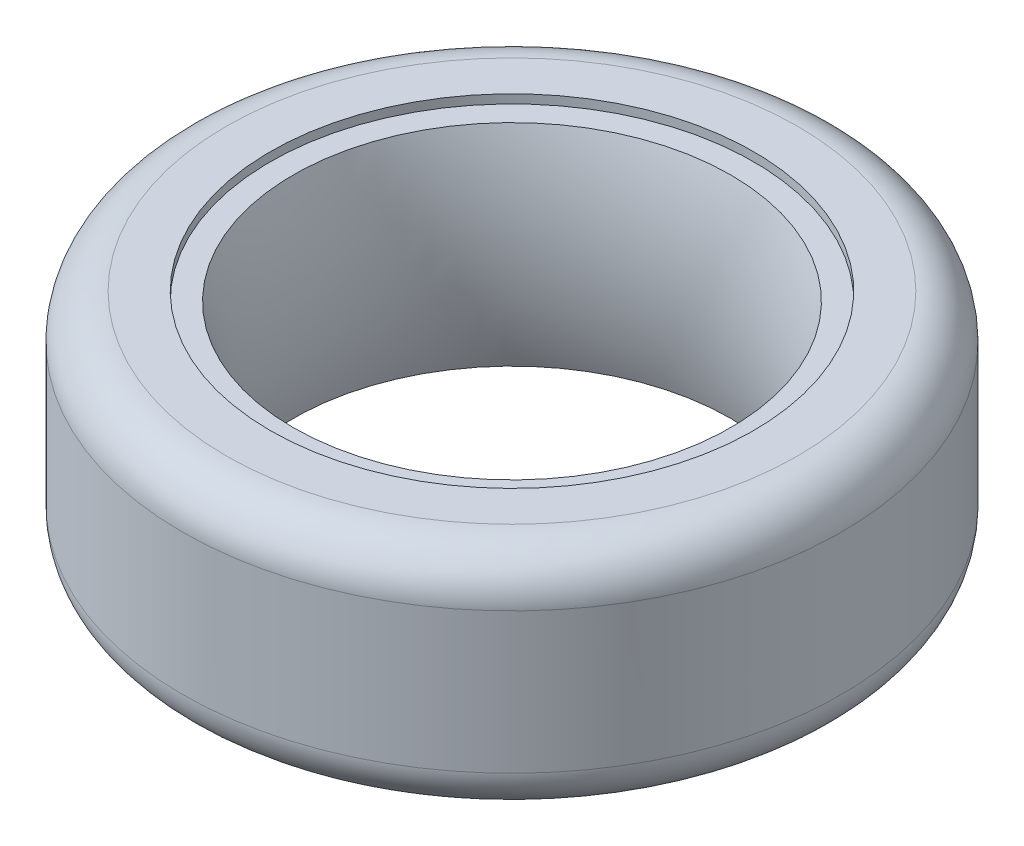
from build123d import *

# Parameters (mm, degrees)
FILLET1_R = 5


with BuildPart() as part:
    # Sketch1 → Revolve3 (revolve)
    with BuildSketch(Plane.XY):
        with BuildLine():
            Line((-27.5, -13), (-27.5, -12))
            Line((-27.5, -12), (-24.9, -12))
            ThreePointArc((-24.9, -12), (-23.057568057, 0), (-24.9, 12))
            Line((-24.9, 12), (-27.5, 12))
            Line((-27.5, 12), (-27.5, 13))
            Line((-27.5, 13), (-37.5, 13))
            Line((-37.5, 13), (-37.5, -13))
            Line((-37.5, -13), (-27.5, -13))
        make_face()
    revolve(axis=Axis((0, 39.143904287, 0), (0, -1, 0)))

    # Fillet1
    fillet1_edges = [part.edges().sort_by_distance(p)[0] for p in [
        (37.5, -13, 0),
        (37.5, 13, 0),
    ]]
    fillet(fillet1_edges, radius=FILLET1_R)


solid = part.part
